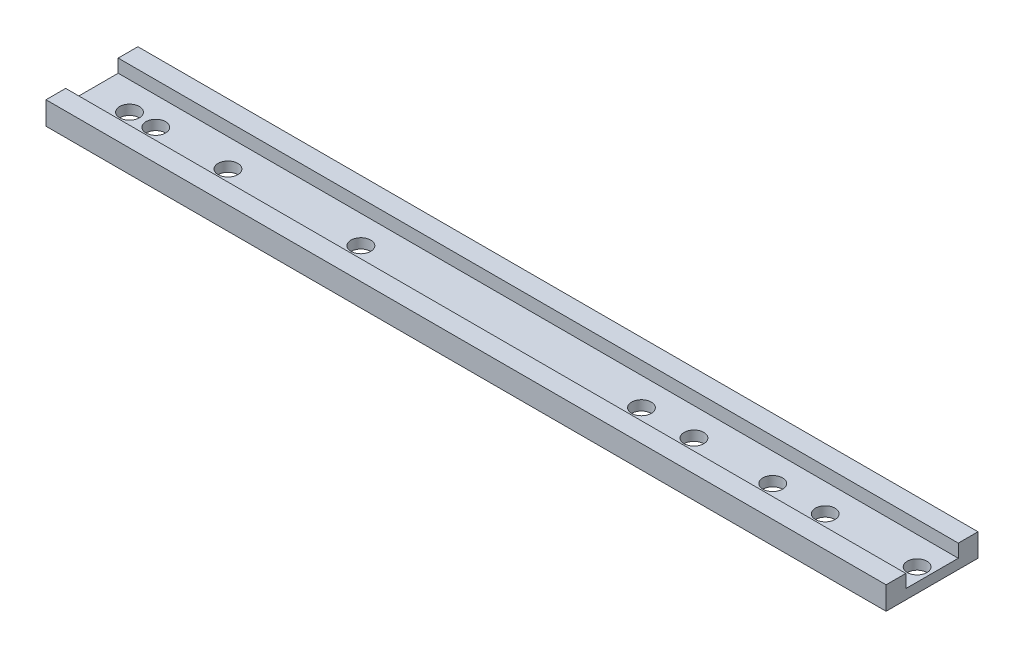
from build123d import *

# Parameters (mm, degrees)
BOSS_EXTRUDE1_DEPTH = 16
SCALE1_SCALE        = 25.4
SKETCH2_R           = 4.7625
CUT_EXTRUDE1_DEPTH  = 12.112499989


with BuildPart() as part:
    # Sketch1 → Boss-Extrude1 (new body)
    with BuildSketch(Plane(origin=(0, 0, 0), x_dir=(0, 0, -1), z_dir=(1, 0, 0))):
        Polygon((0, 0.4375), (0, 0), (1.75, 0), (1.75, 0.4375), (1.375, 0.4375), (1.375, 0.1875), (0.375, 0.1875), (0.375, 0.4375), align=None)
    extrude(amount=BOSS_EXTRUDE1_DEPTH)


with BuildPart() as part_1:
    # Scale1: scaled about (8, 0.173295455, -0.875)
    add(part.part.scale(SCALE1_SCALE).moved(Location((-195.2, -4.228409102, 21.35))))

    # Sketch2 → Cut-Extrude1 (cut, through all)
    with BuildSketch(Plane.XZ.offset(4.228409091)):
        with Locations((-176.15, 0)):
            Circle(SKETCH2_R)
        with Locations((-163.45, 0)):
            Circle(SKETCH2_R)
        with Locations((-128.525, 0)):
            Circle(SKETCH2_R)
        with Locations((-64.23125, 0)):
            Circle(SKETCH2_R)
        with Locations((71.5, 0)):
            Circle(SKETCH2_R)
        with Locations((96.9, 0)):
            Circle(SKETCH2_R)
        with Locations((135, 0)):
            Circle(SKETCH2_R)
        with Locations((160.4, 0)):
            Circle(SKETCH2_R)
        with Locations((204.85, 0)):
            Circle(SKETCH2_R)
    extrude(amount=-CUT_EXTRUDE1_DEPTH, mode=Mode.SUBTRACT)


solid = part_1.part
